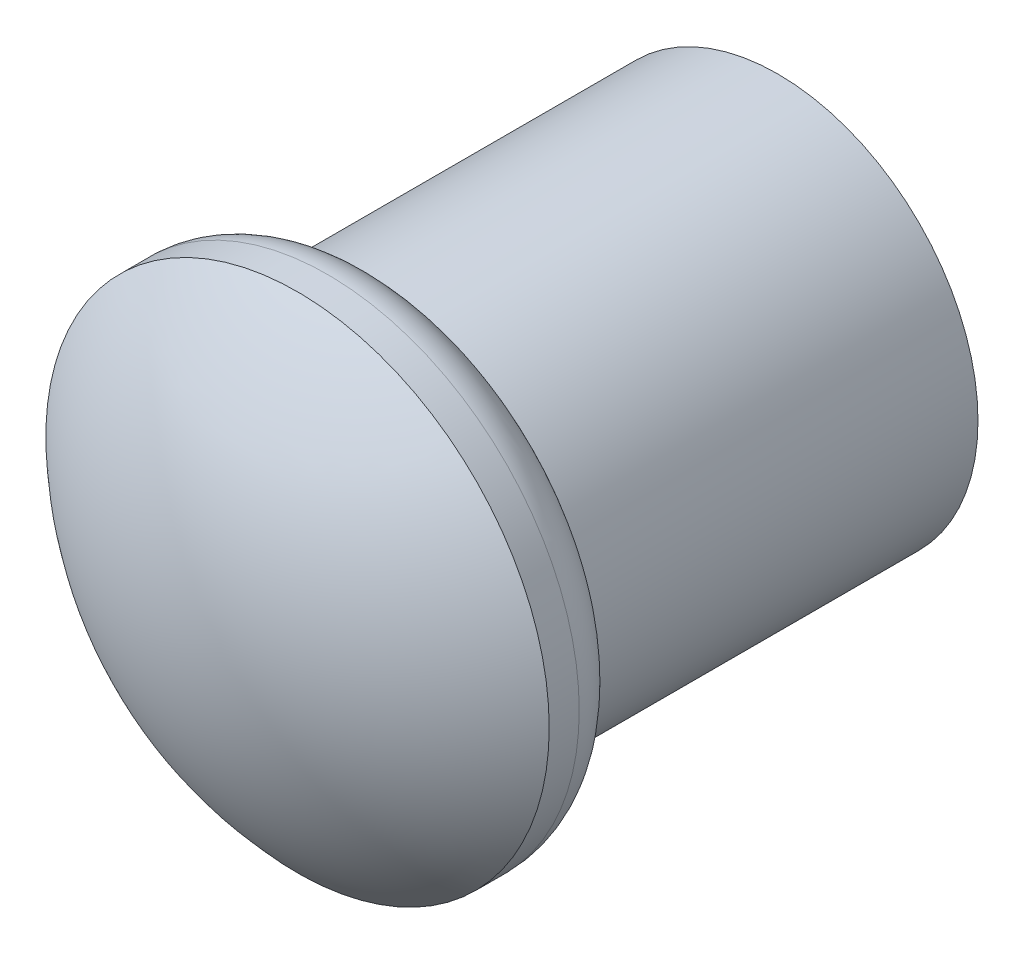
from build123d import *

# Parameters (mm, degrees)
SKETCH1_R           = 5
BOSS_EXTRUDE1_DEPTH = 10
SKETCH3_R           = 6.288052198
BOSS_EXTRUDE2_DEPTH = 2
DOME1_FACE_RADIUS   = 6.288052198
DOME1_HEIGHT        = 2.5
FILLET3_R           = 1.25


with BuildPart() as part:
    # Sketch1 → Boss-Extrude1 (new body)
    with BuildSketch(Plane.XY):
        with Locations((-81.69248982, 187.117376864)):
            Circle(SKETCH1_R)
    extrude(amount=BOSS_EXTRUDE1_DEPTH)

    # Sketch3 → Boss-Extrude2 (add)
    with BuildSketch(Plane.XY.offset(10)):
        with Locations((-81.69248982, 187.117376864)):
            Circle(SKETCH3_R)
    extrude(amount=BOSS_EXTRUDE2_DEPTH)

    # Dome1: a dome of height H over a round flat face of radius A is a cap of a sphere of radius (A * A + H * H) / (2 * H)
    dome1_r = (DOME1_FACE_RADIUS * DOME1_FACE_RADIUS + DOME1_HEIGHT * DOME1_HEIGHT) / (2 * DOME1_HEIGHT)
    dome1_base = Plane((-81.69248982, 187.117376864, 12), z_dir=(0, 0, 1))
    with Locations(dome1_base.offset(DOME1_HEIGHT - dome1_r)):
        dome1_ball = Sphere(dome1_r, mode=Mode.PRIVATE)
    add(split(dome1_ball, bisect_by=dome1_base, keep=Keep.TOP, mode=Mode.PRIVATE))

    # Fillet3
    fillet3_edges = [part.edges().sort_by_distance(p)[0] for p in [
        (-87.980542018, 187.117376864, 10),
    ]]
    fillet(fillet3_edges, radius=FILLET3_R)


solid = part.part
